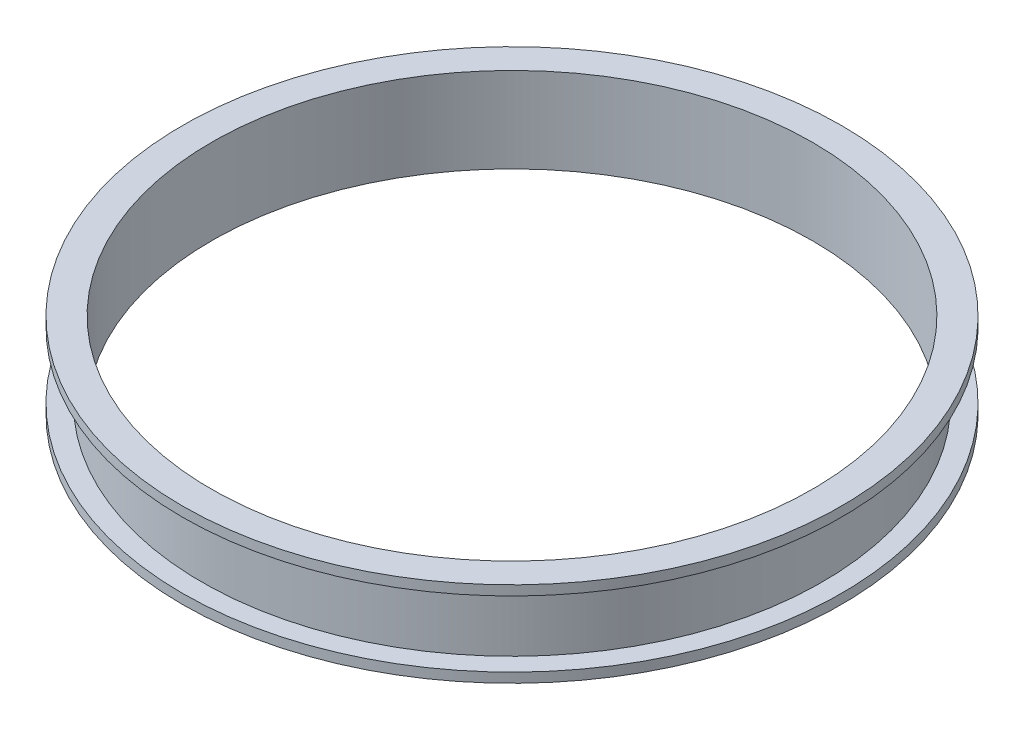
from build123d import *

# Parameters (mm, degrees)
CUT_EXTRUDE1_REACH = 4.5
SKETCH2_R          = 77.5


with BuildPart() as part:
    # Sketch1 → Revolve1 (revolve)
    with BuildSketch(Plane.XY):
        Polygon((0, 0), (77.5, 0), (77.5, 19.5), (85, 19.5), (85, 17), (80, 17), (80, 0), (85, 0), (85, -2.5), (0, -2.5), align=None)
    revolve(axis=Axis((0, -2.5, 0), (0, 1, 0)))

    # Sketch2 → Cut-Extrude1 (cut, up to next)
    with BuildSketch(Plane(origin=(0, 0, 0), x_dir=(1, 0, 0), z_dir=(0, 1, 0)), mode=Mode.PRIVATE) as cut_extrude1_sk1:
        Circle(SKETCH2_R)
    cut_extrude1_tool1 = extrude(cut_extrude1_sk1.sketch, amount=-CUT_EXTRUDE1_REACH, mode=Mode.PRIVATE) & part.part
    add(cut_extrude1_tool1.solids().sort_by_distance((0, 0, 0))[0], mode=Mode.SUBTRACT)


solid = part.part
